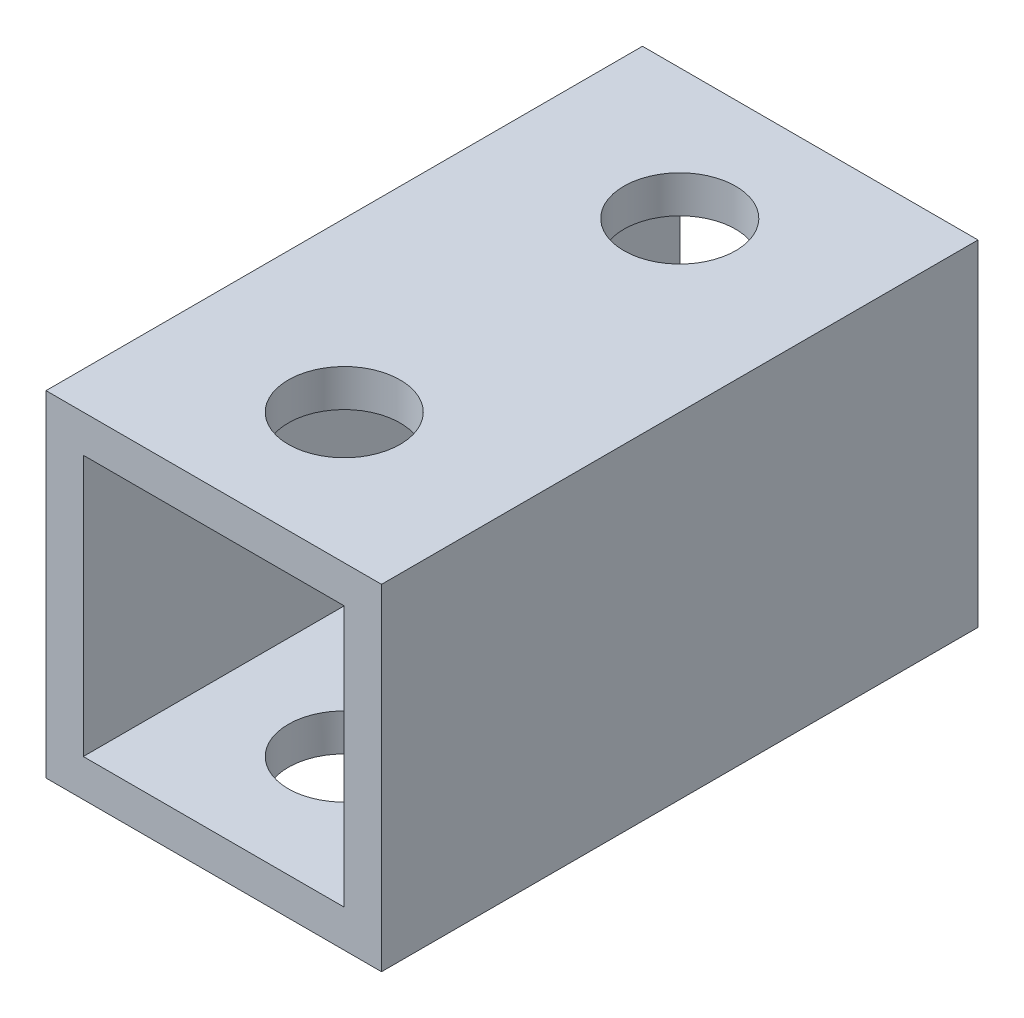
from build123d import *

# Parameters (mm, degrees)
SKETCH_1_W          = 9
SKETCH_1_H          = 9
EXTRUDE_1_DEPTH     = 16
SKETCH_2_W          = 7
SKETCH_2_H          = 7
CUT_EXTRUDE_1_DEPTH = 20
SKETCH_3_R          = 1.5
SKETCH_3_R_2        = 1.499605096
CUT_EXTRUDE_2_DEPTH = 20


with BuildPart() as part:
    # ｽｹｯﾁ1 → ﾎﾞｽ - 押し出し1 (new body)
    with BuildSketch(Plane.XY):
        Rectangle(SKETCH_1_W, SKETCH_1_H)
    extrude(amount=EXTRUDE_1_DEPTH)

    # ｽｹｯﾁ2 → ｶｯﾄ - 押し出し1 (cut)
    with BuildSketch(Plane.XY.offset(16)):
        Rectangle(SKETCH_2_W, SKETCH_2_H)
    extrude(amount=-CUT_EXTRUDE_1_DEPTH, mode=Mode.SUBTRACT)

    # ｽｹｯﾁ3 → ｶｯﾄ - 押し出し2 (cut)
    with BuildSketch(Plane(origin=(0, 4.5, 0), x_dir=(1, 0, 0), z_dir=(0, 1, 0))):
        with Locations((0, -3.5)):
            Circle(SKETCH_3_R)
        with Locations((0, -12.5)):
            Circle(SKETCH_3_R_2)
    extrude(amount=-CUT_EXTRUDE_2_DEPTH, mode=Mode.SUBTRACT)


solid = part.part
